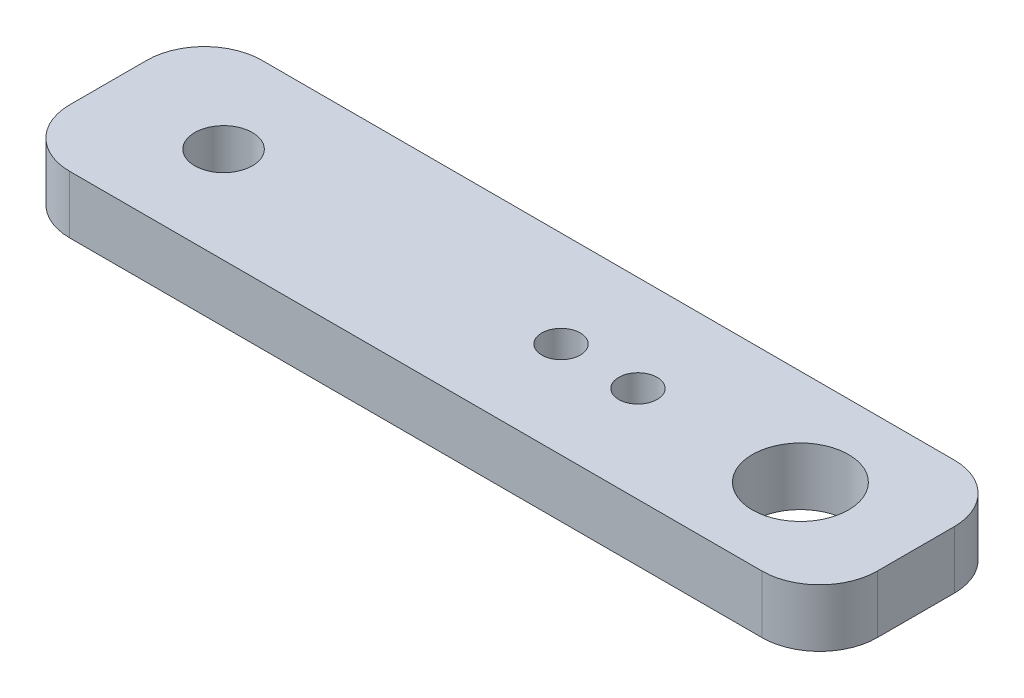
from build123d import *

# Parameters (mm, degrees)
SKETCH1_W             = 42
SKETCH1_H             = 10
BOSS_EXTRUDE1_DEPTH   = 3
F_5_0MM_DOWEL_HOLE1_D = 5
F_3_0MM_DOWEL_HOLE1_D = 3
SKETCH2_R             = 1
CUT_EXTRUDE1_DEPTH    = 3
FILLET1_R             = 3


with BuildPart() as part:
    # Sketch1 → Boss-Extrude1 (new body)
    with BuildSketch(Plane(origin=(0, 0, 0), x_dir=(1, 0, 0), z_dir=(0, 1, 0))):
        Rectangle(SKETCH1_W, SKETCH1_H)
    extrude(amount=BOSS_EXTRUDE1_DEPTH)

    # Ø5.0mm Dowel Hole1 (through all)
    with Locations(Plane(origin=(0, 3, 0), x_dir=(1, 0, 0), z_dir=(0, 1, 0))):
        with Locations((15, 0)):
            Hole(F_5_0MM_DOWEL_HOLE1_D / 2)

    # Ø3.0mm Dowel Hole1 (through all)
    with Locations(Plane(origin=(0, 3, 0), x_dir=(1, 0, 0), z_dir=(0, 1, 0))):
        with Locations((-15, 0)):
            Hole(F_3_0MM_DOWEL_HOLE1_D / 2)

    # Sketch2 → Cut-Extrude1 (cut)
    with BuildSketch(Plane(origin=(0, 3, 0), x_dir=(1, 0, 0), z_dir=(0, 1, 0))):
        with Locations((6.55, 0)):
            Circle(SKETCH2_R)
        with Locations((2.55, 0)):
            Circle(SKETCH2_R)
    extrude(amount=-CUT_EXTRUDE1_DEPTH, mode=Mode.SUBTRACT)

    # Fillet1
    fillet1_edges = [part.edges().sort_by_distance(p)[0] for p in [
        (21, 1.5, 5),
        (-21, 1.5, 5),
        (-21, 1.5, -5),
        (21, 1.5, -5),
    ]]
    fillet(fillet1_edges, radius=FILLET1_R)


solid = part.part
